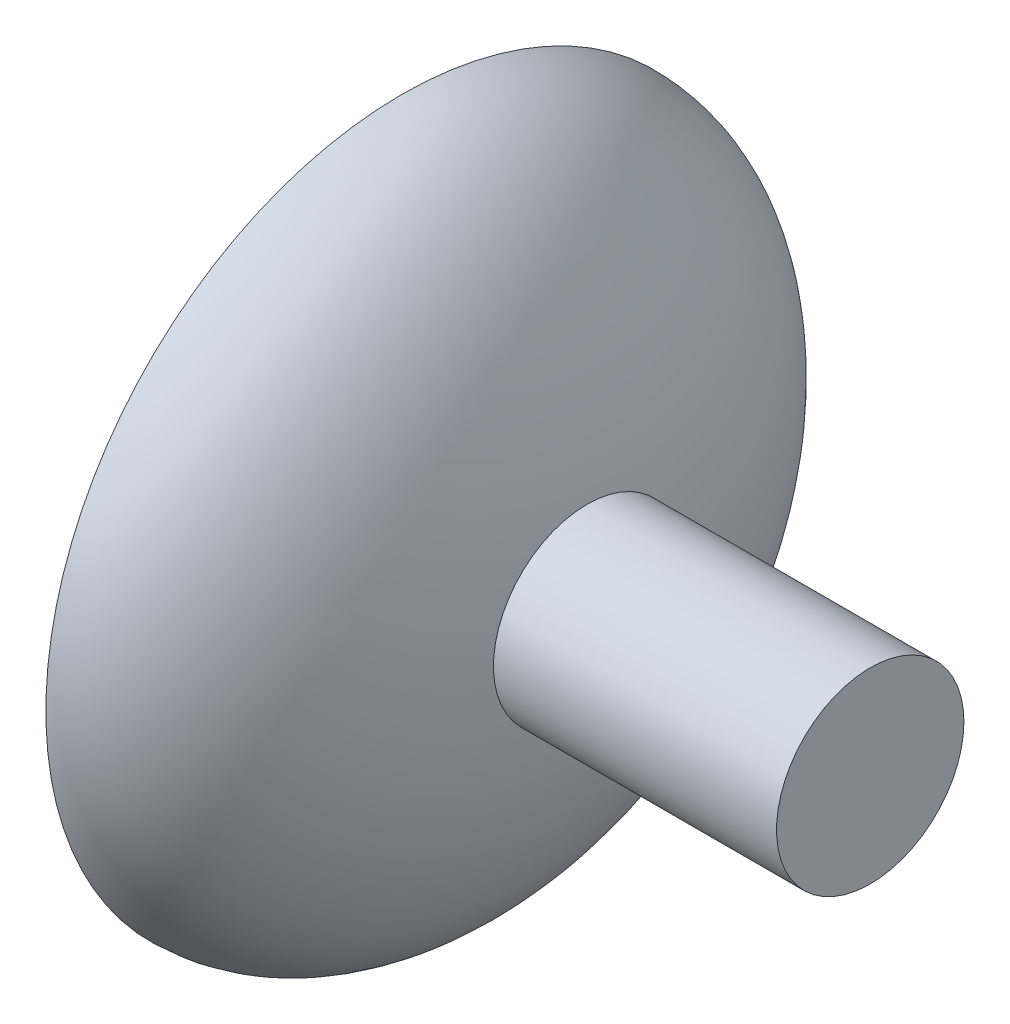
from build123d import *

# Parameters (mm, degrees)
CIRPATTERN1_COUNT   = 12
CUT_EXTRUDE1_DEPTH  = 4.572
SKETCH7_W           = 1.524
SKETCH7_H           = 1.524
CUT_EXTRUDE2_DEPTH  = 9.525
BOSS_EXTRUDE1_REACH = 65.5
SKETCH8_R           = 12.7


with BuildPart() as part:
    # Sketch1 → Revolve2 (revolve)
    with BuildSketch(Plane.XY):
        with BuildLine():
            add(Edge.make_bspline(
                [(0, 48.26), (-26.035, 48.26), (-26.035, 0)],
                knots=[3.141592654, 3.141592654, 3.141592654, 4.71238898, 4.71238898, 4.71238898], degree=2, weights=[1, 0.707106781, 1]))
            Line((-26.035, 0), (-15.875, 0))
            add(Edge.make_bspline(
                [(0, 38.1), (-15.875, 38.1), (-15.875, 0)],
                knots=[3.141592654, 3.141592654, 3.141592654, 4.71238898, 4.71238898, 4.71238898], degree=2, weights=[1, 0.707106781, 1]))
            Line((0, 38.1), (0, 48.26))
        make_face()
    revolve(axis=Axis((-26.035, 0, 0), (1, 0, 0)))

    # Sketch2 → Cut-Loft1 section 0
    with BuildSketch(Plane(origin=(0, -34.29, 0), x_dir=(1, 0, 0), z_dir=(0, 1, 0)), mode=Mode.PRIVATE) as cut_loft1_s0:
        Polygon((0, 7.69896584), (-6.6675, -3.84948292), (6.6675, -3.84948292), align=None)
    cut_loft1 = loft([cut_loft1_s0.sketch, Vertex(0, -45.212, 0)], mode=Mode.SUBTRACT)

    # CirPattern1: Cut-Loft1 ×12 about axis
    cirpattern1_axis = Axis((0, 0, 0), (1, 0, 0))
    for i in range(1, CIRPATTERN1_COUNT):
        add(cut_loft1.rotate(cirpattern1_axis, i * 360 / CIRPATTERN1_COUNT), mode=Mode.SUBTRACT)


with BuildPart() as body_2:
    # Mirror5: mirrored copy
    add(part.part.mirror(Plane(origin=(0, 0, 0), x_dir=(0, 0, 1), z_dir=(1, 0, 0))))

    # Sketch6 → Cut-Extrude1 (cut)
    with BuildSketch(Plane(origin=(0, 0, 0), x_dir=(0, 0, -1), z_dir=(1, 0, 0))):
        Polygon((4.851243253, 42.407942289), (14.134652823, 40.27629228), (14.475716824, 41.761637811), (5.192307254, 43.89328782), align=None)
    cut_extrude1 = extrude(amount=CUT_EXTRUDE1_DEPTH, mode=Mode.SUBTRACT)

    # Sketch7 → Cut-Extrude2 (cut)
    with BuildSketch(Plane(origin=(0, -1.065825004, -4.641704785), x_dir=(1, 0, 0), z_dir=(0, 0.223795276, 0.974636175))):
        with Locations((3.81, 41.656)):
            Rectangle(SKETCH7_W, SKETCH7_H)
    cut_extrude2 = extrude(amount=CUT_EXTRUDE2_DEPTH, mode=Mode.SUBTRACT)

    # Mirror6: Cut-Extrude1, Cut-Extrude2 across plane
    add(cut_extrude1.mirror(Plane(origin=(0, 0, 0), x_dir=(0, 0.223795276, 0.974636175), z_dir=(0, -0.974636175, 0.223795276))), mode=Mode.SUBTRACT)
    add(cut_extrude2.mirror(Plane(origin=(0, 0, 0), x_dir=(0, 0.223795276, 0.974636175), z_dir=(0, -0.974636175, 0.223795276))), mode=Mode.SUBTRACT)

    # Sketch8 → Boss-Extrude1 (add, up to next)
    with BuildSketch(Plane(origin=(63.5, 0, 0), x_dir=(0, 0, -1), z_dir=(1, 0, 0)), mode=Mode.PRIVATE) as boss_extrude1_sk1:
        Circle(SKETCH8_R)
    boss_extrude1_tool1 = extrude(boss_extrude1_sk1.sketch, amount=-BOSS_EXTRUDE1_REACH, mode=Mode.PRIVATE) - body_2.part
    add(boss_extrude1_tool1.solids().sort_by_distance((63.5, 0, 0))[0])


solid = body_2.part
